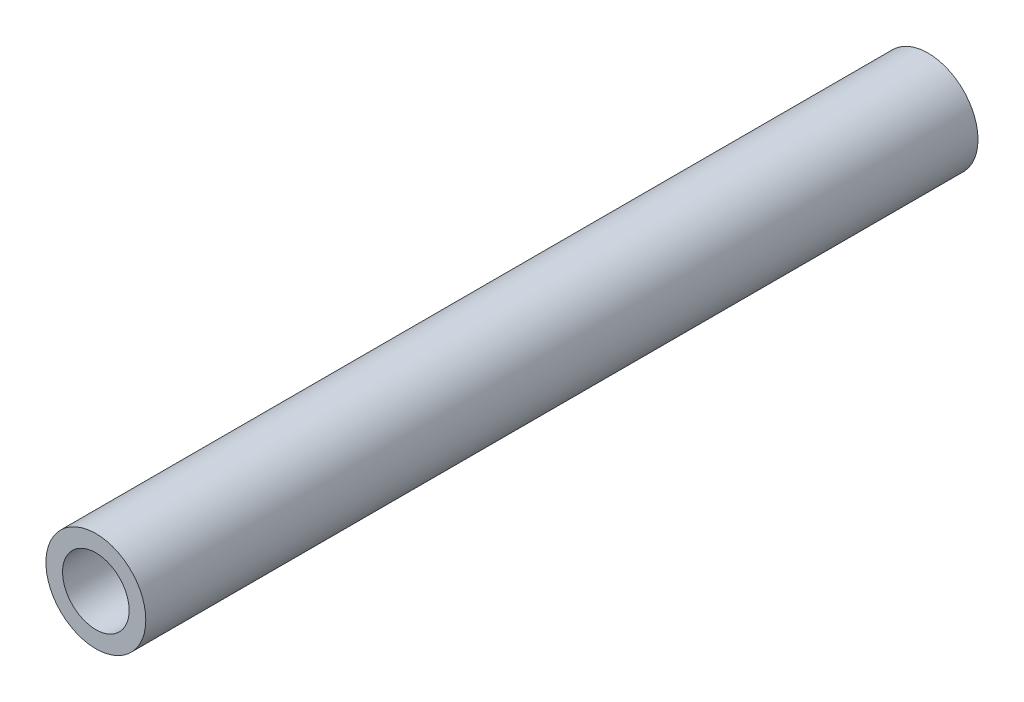
from build123d import *

# Parameters (mm, degrees)
SKETCH1_R           = 3
SKETCH1_R_2         = 2
BOSS_EXTRUDE1_DEPTH = 50


with BuildPart() as part:
    # Sketch1 → Boss-Extrude1 (new body)
    with BuildSketch(Plane.XY):
        Circle(SKETCH1_R)
        Circle(SKETCH1_R_2, mode=Mode.SUBTRACT)
    extrude(amount=BOSS_EXTRUDE1_DEPTH)


solid = part.part
